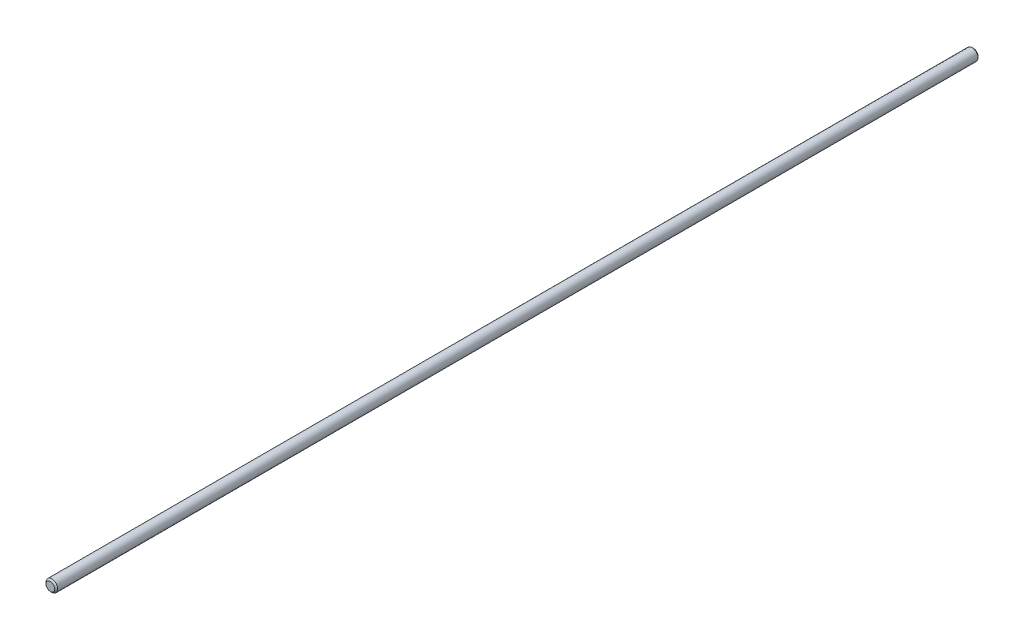
from build123d import *

# Parameters (mm, degrees)
SKETCH1_R           = 4
BOSS_EXTRUDE1_DEPTH = 630
CHAMFER1_SIZE       = 1


with BuildPart() as part:
    # Sketch1 → Boss-Extrude1 (new body)
    with BuildSketch(Plane.XY):
        Circle(SKETCH1_R)
    extrude(amount=BOSS_EXTRUDE1_DEPTH)

    # Chamfer1
    chamfer1_edges = [part.edges().sort_by_distance(p)[0] for p in [
        (-4, 0, 0),
        (-4, 0, 630),
    ]]
    chamfer(chamfer1_edges, length=CHAMFER1_SIZE)


solid = part.part
